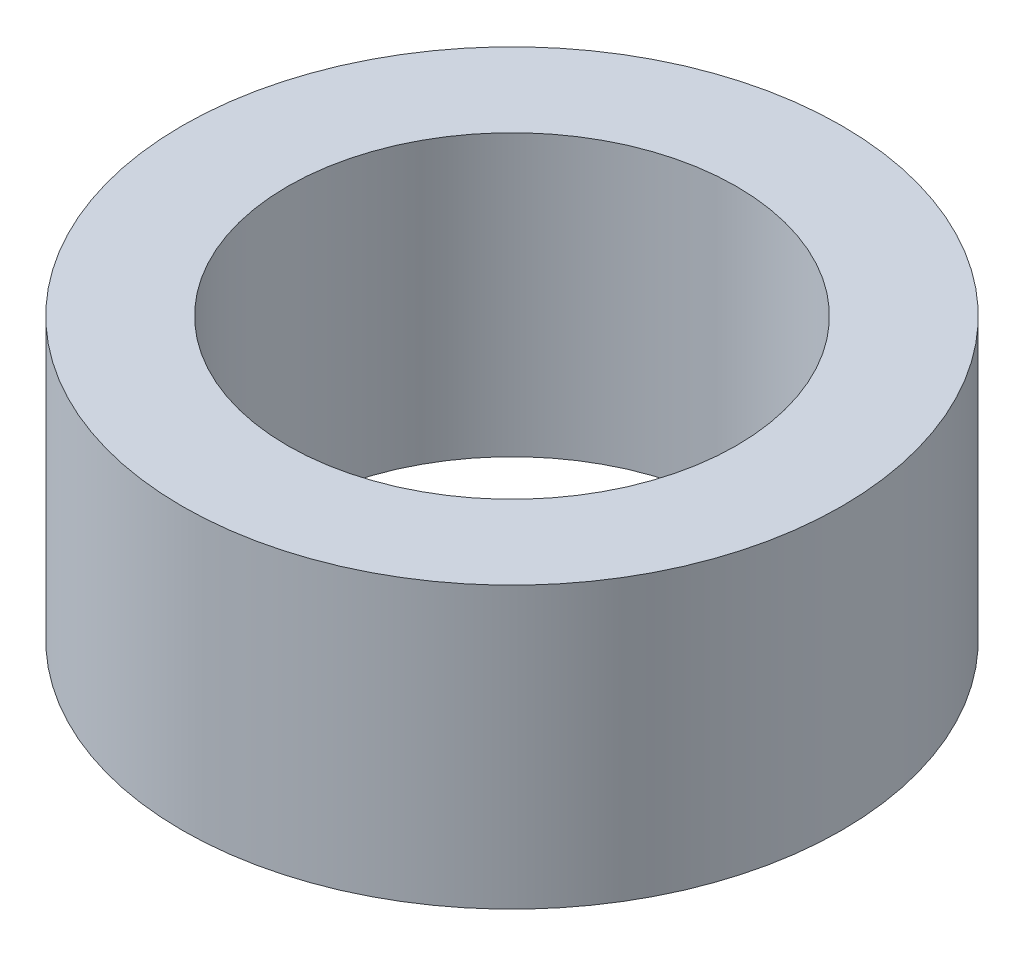
from build123d import *

# Parameters (mm, degrees)
SKETCH1_R           = 2.35
SKETCH1_R_2         = 1.6
BOSS_EXTRUDE1_DEPTH = 2


with BuildPart() as part:
    # Sketch1 → Boss-Extrude1 (new body)
    with BuildSketch(Plane(origin=(0, 0, 0), x_dir=(1, 0, 0), z_dir=(0, 1, 0))):
        Circle(SKETCH1_R)
        Circle(SKETCH1_R_2, mode=Mode.SUBTRACT)
    extrude(amount=BOSS_EXTRUDE1_DEPTH)


solid = part.part
